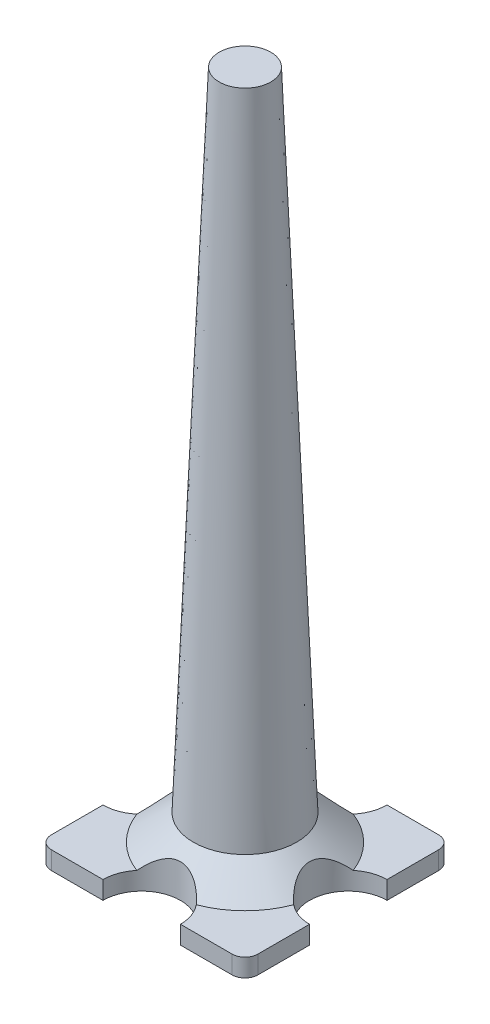
from build123d import *

# Parameters (mm, degrees)
BOSS_EXTRUDE1_DEPTH = 8.89
SKETCH5_R           = 19.05
CUT_EXTRUDE2_DEPTH  = 22.59


with BuildPart() as part:
    # Sketch1 → Boss-Extrude1 (new body)
    with BuildSketch(Plane(origin=(0, 0, 0), x_dir=(1, 0, 0), z_dir=(0, 1, 0))):
        with BuildLine():
            Line((44.45, -50.8), (-44.45, -50.8))
            ThreePointArc((-44.45, -50.8), (-48.940128061, -48.940128061), (-50.8, -44.45))
            Line((-50.8, -44.45), (-50.8, 44.45))
            ThreePointArc((-50.8, 44.45), (-48.940128061, 48.940128061), (-44.45, 50.8))
            Line((-44.45, 50.8), (44.45, 50.8))
            ThreePointArc((44.45, 50.8), (48.940128061, 48.940128061), (50.8, 44.45))
            Line((50.8, 44.45), (50.8, -44.45))
            ThreePointArc((50.8, -44.45), (48.940128061, -48.940128061), (44.45, -50.8))
        make_face()
    extrude(amount=BOSS_EXTRUDE1_DEPTH)

    # Sketch2 → Revolve1 (revolve)
    with BuildSketch(Plane.XY):
        Polygon((0, 8.89), (0, 21.59), (25.4, 21.59), (41.275, 8.89), align=None)
    revolve(axis=Axis((0, 37.971899969, 0), (0, -1, 0)))

    # Sketch5 → Cut-Extrude2 (cut, through all)
    with BuildSketch(Plane(origin=(0, 21.59, 0), x_dir=(1, 0, 0), z_dir=(0, 1, 0))):
        with Locations((0, 50.8)):
            Circle(SKETCH5_R)
        with Locations((50.8, 0)):
            Circle(SKETCH5_R)
        with Locations((0, -50.8)):
            Circle(SKETCH5_R)
        with Locations((-50.8, 0)):
            Circle(SKETCH5_R)
    extrude(amount=-CUT_EXTRUDE2_DEPTH, mode=Mode.SUBTRACT)

    # Sketch6 → Revolve2 (revolve)
    with BuildSketch(Plane.XY):
        Polygon((0, 21.59), (25.4, 21.59), (12.7, 339.09), (0, 339.09), align=None)
    revolve(axis=Axis((0, 0, 0), (0, 1, 0)))


solid = part.part
